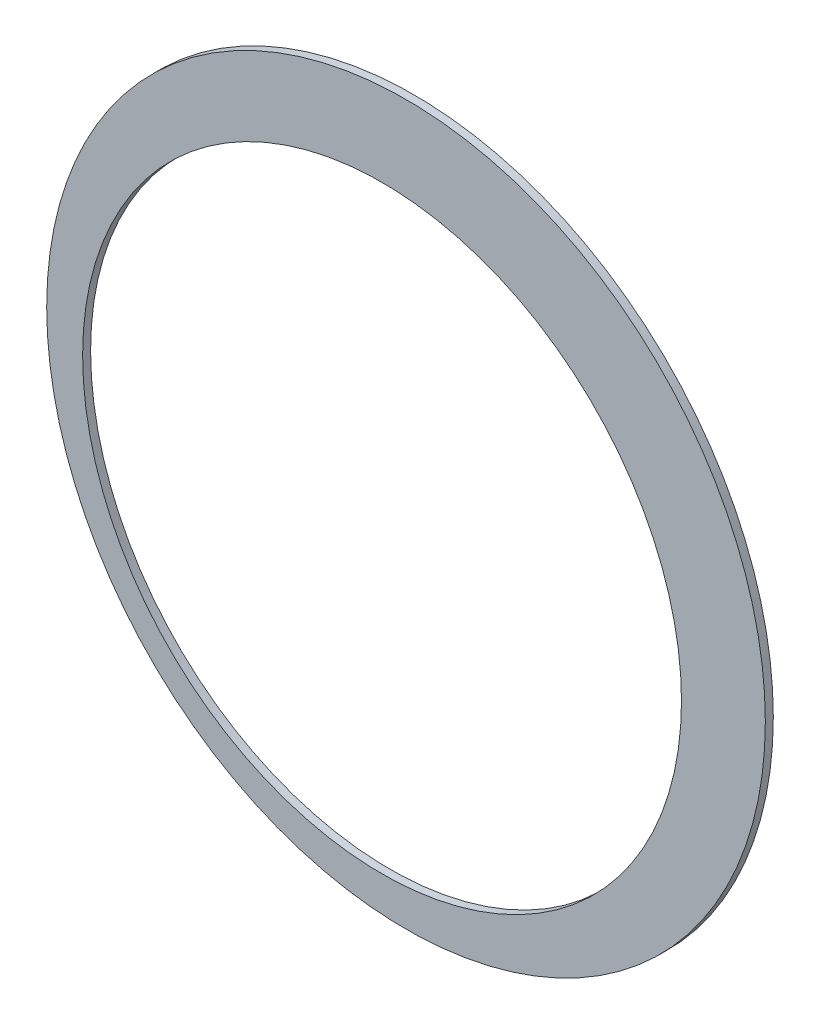
from build123d import *

# Parameters (mm, degrees)
SKETCH2_R          = 45
BASE_EXTRUDE_DEPTH = 1
SKETCH3_R          = 37.5
CUT_EXTRUDE5_DEPTH = 2


with BuildPart() as part:
    # Sketch2 → Base-Extrude (new body)
    with BuildSketch(Plane.XY):
        with Locations((3, 3)):
            Circle(SKETCH2_R)
    extrude(amount=BASE_EXTRUDE_DEPTH)

    # Sketch3 → Cut-Extrude5 (cut, through all)
    with BuildSketch(Plane.XY):
        Circle(SKETCH3_R)
    extrude(amount=CUT_EXTRUDE5_DEPTH, mode=Mode.SUBTRACT)


solid = part.part
